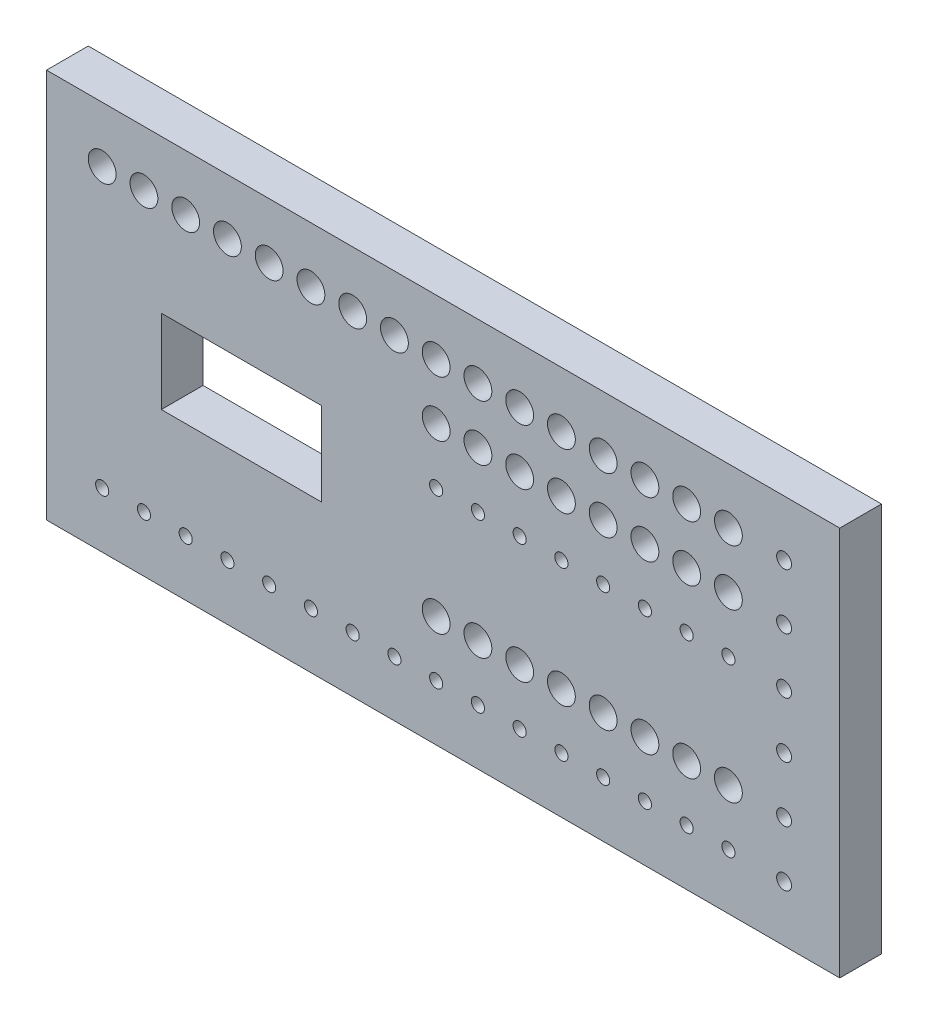
from build123d import *

# Parameters (mm, degrees)
SKETCH1_W           = 361.95
SKETCH1_H           = 177.8
SKETCH1_R           = 6.35
SKETCH1_R_2         = 3
SKETCH1_R_3         = 3.4
SKETCH1_W_2         = 73.025
SKETCH1_H_2         = 38.1
BOSS_EXTRUDE1_DEPTH = 19.05


with BuildPart() as part:
    # Sketch1 → Boss-Extrude1 (new body)
    with BuildSketch(Plane.XY):
        with Locations((106.3625, -11.579089164)):
            Rectangle(SKETCH1_W, SKETCH1_H)
        with Locations((-49.2125, 51.920910836)):
            Circle(SKETCH1_R, mode=Mode.SUBTRACT)
        with Locations((-30.1625, 51.920910836)):
            Circle(SKETCH1_R, mode=Mode.SUBTRACT)
        with Locations((-11.1125, 51.920910836)):
            Circle(SKETCH1_R, mode=Mode.SUBTRACT)
        with Locations((7.9375, 51.920910836)):
            Circle(SKETCH1_R, mode=Mode.SUBTRACT)
        with Locations((26.9875, 51.920910836)):
            Circle(SKETCH1_R, mode=Mode.SUBTRACT)
        with Locations((46.0375, 51.920910836)):
            Circle(SKETCH1_R, mode=Mode.SUBTRACT)
        with Locations((65.0875, 51.920910836)):
            Circle(SKETCH1_R, mode=Mode.SUBTRACT)
        with Locations((84.1375, 51.920910836)):
            Circle(SKETCH1_R, mode=Mode.SUBTRACT)
        with Locations((103.1875, 51.920910836)):
            Circle(SKETCH1_R, mode=Mode.SUBTRACT)
        with Locations((122.2375, 51.920910836)):
            Circle(SKETCH1_R, mode=Mode.SUBTRACT)
        with Locations((141.2875, 51.920910836)):
            Circle(SKETCH1_R, mode=Mode.SUBTRACT)
        with Locations((160.3375, 51.920910836)):
            Circle(SKETCH1_R, mode=Mode.SUBTRACT)
        with Locations((179.3875, 51.920910836)):
            Circle(SKETCH1_R, mode=Mode.SUBTRACT)
        with Locations((198.4375, 51.920910836)):
            Circle(SKETCH1_R, mode=Mode.SUBTRACT)
        with Locations((217.4875, 51.920910836)):
            Circle(SKETCH1_R, mode=Mode.SUBTRACT)
        with Locations((236.5375, 51.920910836)):
            Circle(SKETCH1_R, mode=Mode.SUBTRACT)
        with Locations((103.1875, 26.520910836)):
            Circle(SKETCH1_R, mode=Mode.SUBTRACT)
        with Locations((122.2375, 26.520910836)):
            Circle(SKETCH1_R, mode=Mode.SUBTRACT)
        with Locations((141.2875, 26.520910836)):
            Circle(SKETCH1_R, mode=Mode.SUBTRACT)
        with Locations((160.3375, 26.520910836)):
            Circle(SKETCH1_R, mode=Mode.SUBTRACT)
        with Locations((179.3875, 26.520910836)):
            Circle(SKETCH1_R, mode=Mode.SUBTRACT)
        with Locations((198.4375, 26.520910836)):
            Circle(SKETCH1_R, mode=Mode.SUBTRACT)
        with Locations((217.4875, 26.520910836)):
            Circle(SKETCH1_R, mode=Mode.SUBTRACT)
        with Locations((236.5375, 26.520910836)):
            Circle(SKETCH1_R, mode=Mode.SUBTRACT)
        with Locations((103.1875, -49.679089164)):
            Circle(SKETCH1_R, mode=Mode.SUBTRACT)
        with Locations((122.2375, -49.679089164)):
            Circle(SKETCH1_R, mode=Mode.SUBTRACT)
        with Locations((141.2875, -49.679089164)):
            Circle(SKETCH1_R, mode=Mode.SUBTRACT)
        with Locations((160.3375, -49.679089164)):
            Circle(SKETCH1_R, mode=Mode.SUBTRACT)
        with Locations((179.3875, -49.679089164)):
            Circle(SKETCH1_R, mode=Mode.SUBTRACT)
        with Locations((198.4375, -49.679089164)):
            Circle(SKETCH1_R, mode=Mode.SUBTRACT)
        with Locations((217.4875, -49.679089164)):
            Circle(SKETCH1_R, mode=Mode.SUBTRACT)
        with Locations((236.5375, -49.679089164)):
            Circle(SKETCH1_R, mode=Mode.SUBTRACT)
        with Locations((103.1875, 1.120910836)):
            Circle(SKETCH1_R_2, mode=Mode.SUBTRACT)
        with Locations((122.2375, 1.120910836)):
            Circle(SKETCH1_R_2, mode=Mode.SUBTRACT)
        with Locations((141.2875, 1.120910836)):
            Circle(SKETCH1_R_2, mode=Mode.SUBTRACT)
        with Locations((160.3375, 1.120910836)):
            Circle(SKETCH1_R_2, mode=Mode.SUBTRACT)
        with Locations((179.3875, 1.120910836)):
            Circle(SKETCH1_R_2, mode=Mode.SUBTRACT)
        with Locations((198.4375, 1.120910836)):
            Circle(SKETCH1_R_2, mode=Mode.SUBTRACT)
        with Locations((217.4875, 1.120910836)):
            Circle(SKETCH1_R_2, mode=Mode.SUBTRACT)
        with Locations((236.5375, 1.120910836)):
            Circle(SKETCH1_R_2, mode=Mode.SUBTRACT)
        with Locations((-49.2125, -75.079089164)):
            Circle(SKETCH1_R_2, mode=Mode.SUBTRACT)
        with Locations((-30.1625, -75.079089164)):
            Circle(SKETCH1_R_2, mode=Mode.SUBTRACT)
        with Locations((-11.1125, -75.079089164)):
            Circle(SKETCH1_R_2, mode=Mode.SUBTRACT)
        with Locations((7.9375, -75.079089164)):
            Circle(SKETCH1_R_2, mode=Mode.SUBTRACT)
        with Locations((26.9875, -75.079089164)):
            Circle(SKETCH1_R_2, mode=Mode.SUBTRACT)
        with Locations((46.0375, -75.079089164)):
            Circle(SKETCH1_R_2, mode=Mode.SUBTRACT)
        with Locations((65.0875, -75.079089164)):
            Circle(SKETCH1_R_2, mode=Mode.SUBTRACT)
        with Locations((84.1375, -75.079089164)):
            Circle(SKETCH1_R_2, mode=Mode.SUBTRACT)
        with Locations((103.1875, -75.079089164)):
            Circle(SKETCH1_R_2, mode=Mode.SUBTRACT)
        with Locations((122.2375, -75.079089164)):
            Circle(SKETCH1_R_2, mode=Mode.SUBTRACT)
        with Locations((141.2875, -75.079089164)):
            Circle(SKETCH1_R_2, mode=Mode.SUBTRACT)
        with Locations((160.3375, -75.079089164)):
            Circle(SKETCH1_R_2, mode=Mode.SUBTRACT)
        with Locations((179.3875, -75.079089164)):
            Circle(SKETCH1_R_2, mode=Mode.SUBTRACT)
        with Locations((198.4375, -75.079089164)):
            Circle(SKETCH1_R_2, mode=Mode.SUBTRACT)
        with Locations((217.4875, -75.079089164)):
            Circle(SKETCH1_R_2, mode=Mode.SUBTRACT)
        with Locations((236.5375, -75.079089164)):
            Circle(SKETCH1_R_2, mode=Mode.SUBTRACT)
        with Locations((261.9375, 51.920910836)):
            Circle(SKETCH1_R_3, mode=Mode.SUBTRACT)
        with Locations((261.9375, 26.520910836)):
            Circle(SKETCH1_R_3, mode=Mode.SUBTRACT)
        with Locations((261.9375, -24.279089164)):
            Circle(SKETCH1_R_3, mode=Mode.SUBTRACT)
        with Locations((261.9375, -75.079089164)):
            Circle(SKETCH1_R_3, mode=Mode.SUBTRACT)
        with Locations((261.9375, -49.679089164)):
            Circle(SKETCH1_R_3, mode=Mode.SUBTRACT)
        with Locations((261.9375, 1.120910836)):
            Circle(SKETCH1_R_3, mode=Mode.SUBTRACT)
        with Locations((14.2875, -11.579089164)):
            Rectangle(SKETCH1_W_2, SKETCH1_H_2, mode=Mode.SUBTRACT)
    extrude(amount=BOSS_EXTRUDE1_DEPTH)


solid = part.part
